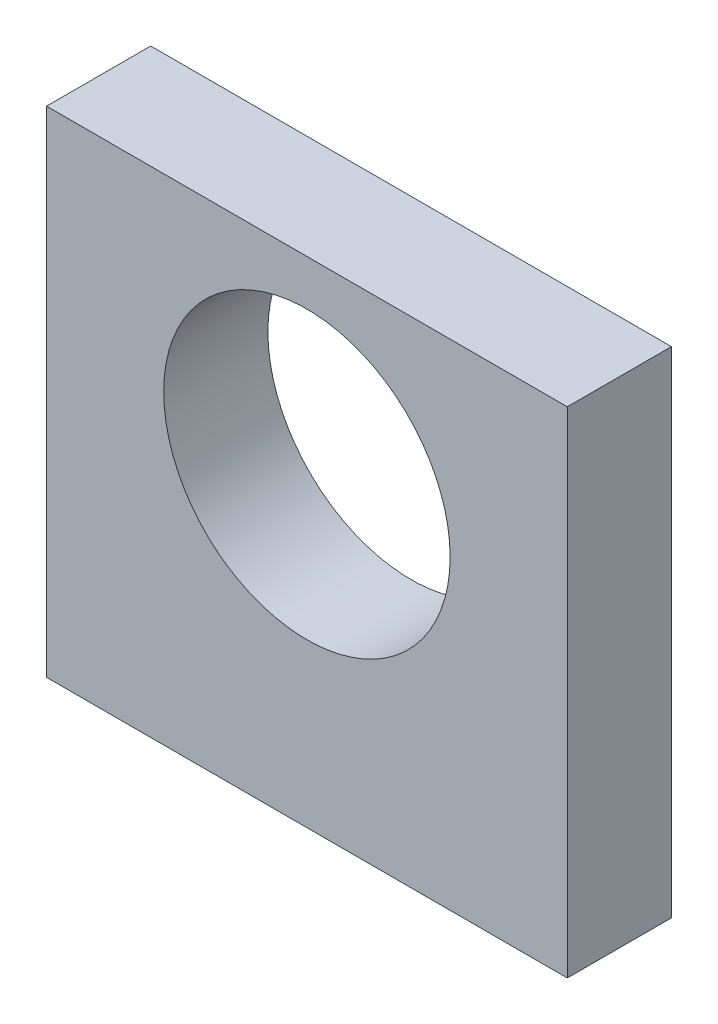
from build123d import *

# Parameters (mm, degrees)
ESBO_O1_W                                         = 40
ESBO_O1_H                                         = 38
RESSALTO_EXTRUS_O1_DEPTH                          = 8
ESBO_O2_R                                         = 11
CORTE_EXTRUS_O1_DEPTH                             = 9
FURO_ROSCADO_PARA_CONDU_TE_DE_M3X0_51_D           = 3.15
FURO_ROSCADO_PARA_CONDU_TE_DE_M3X0_51_DEPTH       = 10
FURO_ROSCADO_PARA_CONDU_TE_DE_M3X0_51_CSINK_D     = 3.766
FURO_ROSCADO_PARA_CONDU_TE_DE_M3X0_51_CSINK_ANGLE = 90
FURO_ROSCADO_PARA_CONDU_TE_DE_M3X0_51_TIP         = 0.946355475


with BuildPart() as part:
    # Esboço1 → Ressalto-extrusão1 (new body)
    with BuildSketch(Plane.XY):
        Rectangle(ESBO_O1_W, ESBO_O1_H)
    extrude(amount=RESSALTO_EXTRUS_O1_DEPTH)

    # Esboço2 → Corte-extrusão1 (cut, through all)
    with BuildSketch(Plane.XY.offset(8)):
        with Locations((0, 4.5)):
            Circle(ESBO_O2_R)
    extrude(amount=-CORTE_EXTRUS_O1_DEPTH, mode=Mode.SUBTRACT)

    # Furo roscado para conduíte de M3x0.51
    with Locations(Plane(origin=(0, -19, 0), x_dir=(-1, 0, 0), z_dir=(0, -1, 0))):
        with Locations((-12, -4), (12, -4)):
            CounterSinkHole(FURO_ROSCADO_PARA_CONDU_TE_DE_M3X0_51_D / 2, FURO_ROSCADO_PARA_CONDU_TE_DE_M3X0_51_CSINK_D / 2, depth=FURO_ROSCADO_PARA_CONDU_TE_DE_M3X0_51_DEPTH, counter_sink_angle=FURO_ROSCADO_PARA_CONDU_TE_DE_M3X0_51_CSINK_ANGLE)
            with Locations((0, 0, -(FURO_ROSCADO_PARA_CONDU_TE_DE_M3X0_51_DEPTH + FURO_ROSCADO_PARA_CONDU_TE_DE_M3X0_51_TIP / 2))):  # 118° drill point
                Cone(0, FURO_ROSCADO_PARA_CONDU_TE_DE_M3X0_51_D / 2, FURO_ROSCADO_PARA_CONDU_TE_DE_M3X0_51_TIP, mode=Mode.SUBTRACT)


solid = part.part
